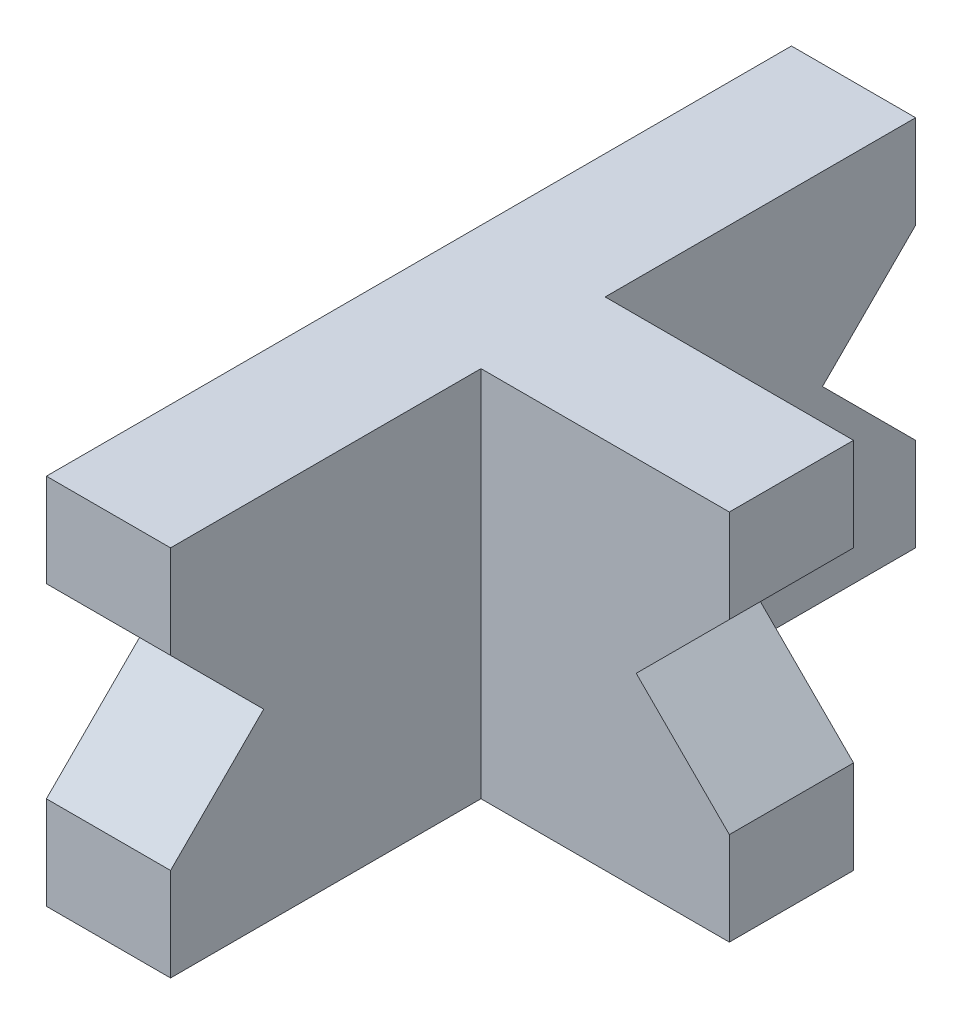
from build123d import *

# Parameters (mm, degrees)
SKETCH1_W           = 120
SKETCH1_H           = 60
BOSS_EXTRUDE1_DEPTH = 20
CUT_EXTRUDE1_DEPTH  = 20
BOSS_EXTRUDE2_DEPTH = 10


with BuildPart() as part:
    # Sketch1 → Boss-Extrude1 (new body)
    with BuildSketch(Plane(origin=(0, 0, 0), x_dir=(0, 0, -1), z_dir=(1, 0, 0))):
        Rectangle(SKETCH1_W, SKETCH1_H)
    extrude(amount=BOSS_EXTRUDE1_DEPTH)

    # Sketch3 → Cut-Extrude1 (cut)
    with BuildSketch(Plane.ZY):
        Polygon((45, 0), (60, -15), (60, 15), align=None)
    cut_extrude1 = extrude(amount=-CUT_EXTRUDE1_DEPTH, mode=Mode.SUBTRACT)

    # Mirror4: Cut-Extrude1 across plane
    add(cut_extrude1.mirror(Plane(origin=(0, 0, 0), x_dir=(1, 0, 0), z_dir=(0, 0, -1))), mode=Mode.SUBTRACT)

    # Sketch4 → Boss-Extrude2 (add, symmetric)
    with BuildSketch(Plane.XY):
        Polygon((20, 30), (60, 30), (60, 15), (45, 0), (60, -15), (60, -30), (20, -30), align=None)
    extrude(amount=BOSS_EXTRUDE2_DEPTH, both=True)


solid = part.part
